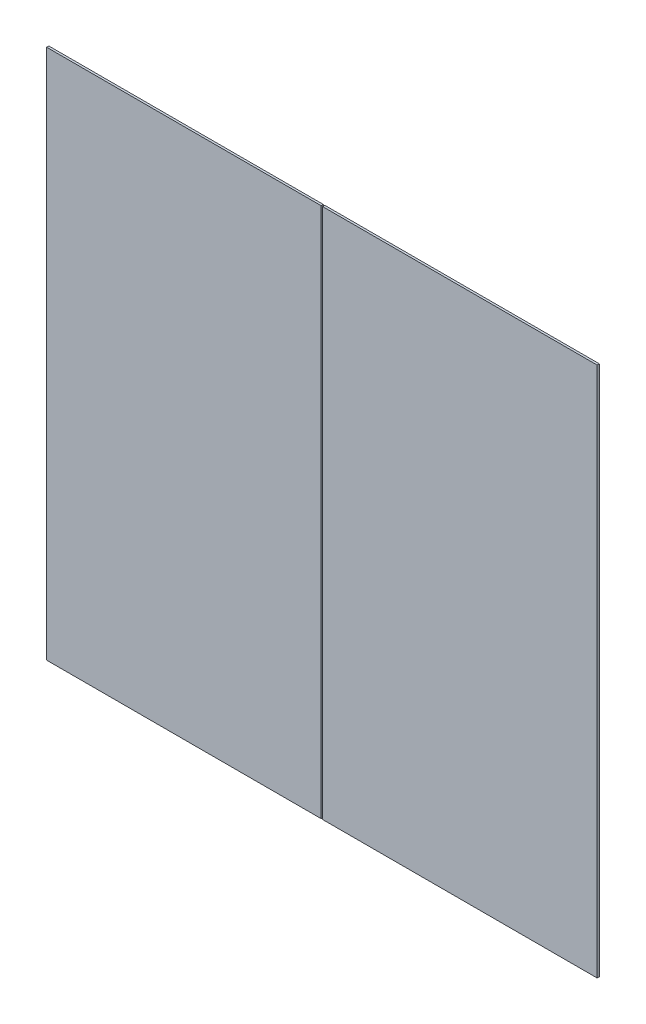
from build123d import *

# Parameters (mm, degrees)
SKETCH1_W             = 1205.865
SKETCH1_H             = 2332.228
BOSS_EXTRUDE1_DEPTH   = 9.525
BOSS_EXTRUDE1_2_DEPTH = 9.525


with BuildPart() as part:
    # Sketch1 → Boss-Extrude1 (new body)
    with BuildSketch(Plane.XY):
        with Locations((-606.1075, 0)):
            Rectangle(SKETCH1_W, SKETCH1_H)
    extrude(amount=BOSS_EXTRUDE1_DEPTH)


with BuildPart() as body_2:
    # Sketch1 → Boss-Extrude1 2 (new body)
    with BuildSketch(Plane.XY):
        with Locations((606.1075, 0)):
            Rectangle(SKETCH1_W, SKETCH1_H)
    extrude(amount=BOSS_EXTRUDE1_2_DEPTH)


solid = Compound([part.part, body_2.part])
